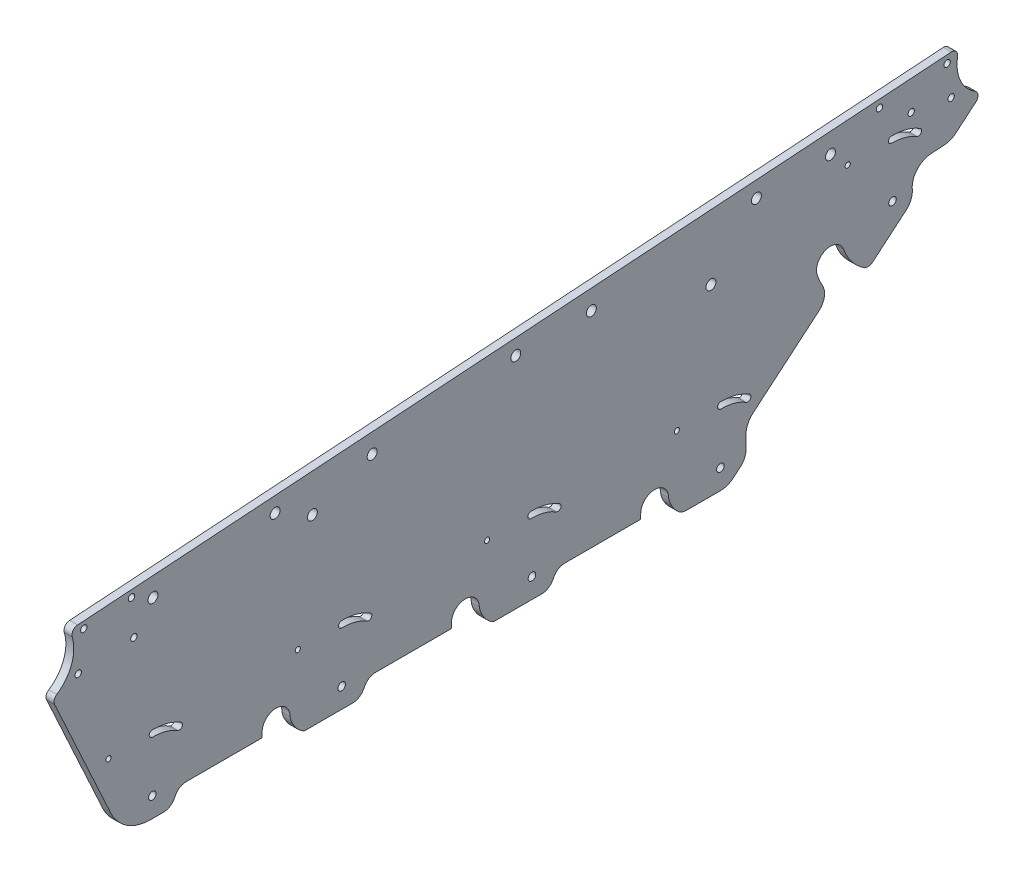
from build123d import *

# Parameters (mm, degrees)
SKETCH_1_R      = 2.5
SKETCH_1_R_2    = 1.6
SKETCH_1_R_3    = 1.3
SKETCH_1_R_4    = 1.9
EXTRUDE_1_DEPTH = 4


with BuildPart() as part:
    # 草图1 → 凸台-拉伸1 (new body)
    with BuildSketch(Plane.ZY):
        with BuildLine():
            Line((79.941847196, 312.779286974), (79.941847196, 310.37938842))
            Line((79.941847196, 310.37938842), (118.048778684, 310.37938842))
            ThreePointArc((118.048778684, 310.37938842), (121.212295154, 309.477639448), (123.424912382, 307.043442935))
            ThreePointArc((123.424912382, 307.043442935), (123.908451597, 306.156590075), (124.459804418, 305.310228312))
            ThreePointArc((124.459804418, 305.310228312), (126.599767036, 303.449448704), (129.355274977, 302.779286974))
            Line((129.355274977, 302.779286974), (135.846674735, 302.779286974))
            ThreePointArc((135.846674735, 302.779286974), (147.714917725, 306.255118752), (155.832977431, 315.5843044))
            Line((155.832977431, 315.5843044), (184.100349844, 377.02653737))
            ThreePointArc((184.100349844, 377.02653737), (184.25423495, 379.122829036), (182.994670387, 380.805569803))
            ThreePointArc((182.994670387, 380.805569803), (175.575423742, 390.035917566), (175.217785471, 401.873004854))
            ThreePointArc((175.217785471, 401.873004854), (174.813539386, 404.446095635), (172.549129806, 405.733208807))
            Line((172.549129806, 405.733208807), (-265.913463366, 435.515010668))
            ThreePointArc((-265.913463366, 435.515010668), (-268.349260645, 434.525893618), (-269.070634733, 431.997835004))
            ThreePointArc((-269.070634733, 431.997835004), (-270.458967767, 420.871071163), (-277.882819523, 412.467573839))
            ThreePointArc((-277.882819523, 412.467573839), (-279.312515533, 410.13392022), (-278.252765969, 407.610648385))
            Line((-278.252765969, 407.610648385), (-268.246230566, 399.190213281))
            ThreePointArc((-268.246230566, 399.190213281), (-265.544431584, 397.566061892), (-262.471282959, 396.863678095))
            Line((-262.471282959, 396.863678095), (-255.629318556, 396.408593428))
            ThreePointArc((-255.629318556, 396.408593428), (-248.6530075, 392.882824378), (-246.344722675, 385.41477346))
            ThreePointArc((-246.344722675, 385.41477346), (-245.547224173, 381.106497376), (-242.780709967, 377.708903254))
            Line((-242.780709967, 377.708903254), (-225.96618646, 363.559589999))
            ThreePointArc((-225.96618646, 363.559589999), (-224.259021966, 363.148943594), (-222.527086507, 363.437804541))
            ThreePointArc((-222.527086507, 363.437804541), (-216.093640019, 369.198004343), (-211.901591148, 376.74756471))
            ThreePointArc((-211.901591148, 376.74756471), (-202.96771311, 381.012048641), (-198.703229179, 372.078170603))
            ThreePointArc((-198.703229179, 372.078170603), (-199.907426668, 369.068297365), (-201.351406018, 366.165823913))
            ThreePointArc((-201.351406018, 366.165823913), (-202.203284687, 360.847165515), (-199.49001514, 356.193995329))
            Line((-199.49001514, 356.193995329), (-166.466058225, 328.404548243))
            ThreePointArc((-166.466058225, 328.404548243), (-163.838636178, 324.972953793), (-162.904676824, 320.753130691))
            Line((-162.904676824, 320.753130691), (-162.904676824, 314.217366152))
            ThreePointArc((-162.904676824, 314.217366152), (-162.15750934, 310.841507671), (-160.055571702, 308.096232111))
            Line((-160.055571702, 308.096232111), (-156.52807865, 305.127869423))
            ThreePointArc((-156.52807865, 305.127869423), (-153.516253341, 303.384762625), (-150.089460052, 302.779286974))
            Line((-150.089460052, 302.779286974), (-132.962822931, 302.779286974))
            ThreePointArc((-132.962822931, 302.779286974), (-131.057359543, 303.089892518), (-129.349178653, 303.989550548))
            ThreePointArc((-129.349178653, 303.989550548), (-127.378799895, 305.843763559), (-125.854682643, 308.079286974))
            ThreePointArc((-125.854682643, 308.079286974), (-124.70730834, 310.334067306), (-124.058152804, 312.779286974))
            ThreePointArc((-124.058152804, 312.779286974), (-117.058152804, 319.779286974), (-110.058152804, 312.779286974))
            Line((-110.058152804, 312.779286974), (-110.058152804, 310.375194841))
            Line((-110.058152804, 310.375194841), (-71.897768127, 310.375194841))
            ThreePointArc((-71.897768127, 310.375194841), (-68.768086545, 309.494285893), (-66.557393134, 307.110225907))
            ThreePointArc((-66.557393134, 307.110225907), (-65.945300527, 306.047683601), (-65.231544729, 305.050584724))
            ThreePointArc((-65.231544729, 305.050584724), (-63.141167069, 303.376870223), (-60.530823557, 302.779286974))
            Line((-60.530823557, 302.779286974), (-36.305637158, 302.779286974))
            ThreePointArc((-36.305637158, 302.779286974), (-33.16644373, 305.003787341), (-30.854682657, 308.079286974))
            ThreePointArc((-30.854682657, 308.079286974), (-29.707305648, 310.334074366), (-29.058150487, 312.779301913))
            ThreePointArc((-29.058150487, 312.779301913), (-22.058145334, 319.779284657), (-15.058155121, 312.779286974))
            Line((-15.058155121, 312.779286974), (-15.058155121, 310.354804619))
            Line((-15.058155121, 310.354804619), (23.075565874, 310.354804619))
            ThreePointArc((23.075565874, 310.354804619), (26.234507213, 309.455891721), (28.446910847, 307.028501158))
            ThreePointArc((28.446910847, 307.028501158), (28.930044794, 306.145924462), (29.48046838, 305.303669209))
            ThreePointArc((29.48046838, 305.303669209), (31.619349297, 303.447603066), (34.37128438, 302.779286974))
            Line((34.37128438, 302.779286974), (58.694362842, 302.779286974))
            ThreePointArc((58.694362842, 302.779286974), (61.833556273, 305.00378734), (64.14531735, 308.079286974))
            ThreePointArc((64.14531735, 308.079286974), (65.292691668, 310.334067319), (65.941847214, 312.779287004))
            ThreePointArc((65.941847214, 312.779287004), (72.94184722, 319.77928698), (79.941847196, 312.779286974))
        make_face()
        with Locations((134.697589837, 398.714435962)):
            Circle(SKETCH_1_R, mode=Mode.SUBTRACT)
        with Locations((-205.302410163, 421.329108832)):
            Circle(SKETCH_1_R, mode=Mode.SUBTRACT)
        with Locations((24.697589837, 406.030947773)):
            Circle(SKETCH_1_R, mode=Mode.SUBTRACT)
        with Locations((54.697589837, 394.714435962)):
            Circle(SKETCH_1_R, mode=Mode.SUBTRACT)
        with Locations((-145.302410163, 394.714435962)):
            Circle(SKETCH_1_R, mode=Mode.SUBTRACT)
        with Locations((-85.302410163, 413.347459584)):
            Circle(SKETCH_1_R, mode=Mode.SUBTRACT)
        with Locations((-229.912547558, 429.226877683)):
            Circle(SKETCH_1_R_2, mode=Mode.SUBTRACT)
        with Locations((-263.830685058, 431.584832)):
            Circle(SKETCH_1_R_2, mode=Mode.SUBTRACT)
        with Locations((-245.82758059, 419.331621378)):
            Circle(SKETCH_1_R_2, mode=Mode.SUBTRACT)
        with Locations((-213.924753581, 412.419296618)):
            Circle(SKETCH_1_R_3, mode=Mode.SUBTRACT)
        with Locations((-265.82758059, 415.709933316)):
            Circle(SKETCH_1_R_2, mode=Mode.SUBTRACT)
        with Locations((145.452321386, 404.165877908)):
            Circle(SKETCH_1_R_2, mode=Mode.SUBTRACT)
        with Locations((172.223627163, 384.384644706)):
            Circle(SKETCH_1_R_2, mode=Mode.SUBTRACT)
        with Locations((169.397149412, 402.539467503)):
            Circle(SKETCH_1_R_2, mode=Mode.SUBTRACT)
        with Locations((144.282792088, 386.203912503)):
            Circle(SKETCH_1_R_2, mode=Mode.SUBTRACT)
        with Locations((-236.412834805, 385.419296624)):
            Circle(SKETCH_1_R_4, mode=Mode.SUBTRACT)
        with Locations((-128.211318153, 339.779286974)):
            Circle(SKETCH_1_R_3, mode=Mode.SUBTRACT)
        with Locations((62, 339.779286968)):
            Circle(SKETCH_1_R_3, mode=Mode.SUBTRACT)
        with Locations((40, 312.779286974)):
            Circle(SKETCH_1_R_4, mode=Mode.SUBTRACT)
        with Locations((-47.3651173, 412.828527404)):
            Circle(SKETCH_1_R, mode=Mode.SUBTRACT)
        with Locations((-55.488081224, 312.779286974)):
            Circle(SKETCH_1_R_4, mode=Mode.SUBTRACT)
        with Locations((-33, 339.779286968)):
            Circle(SKETCH_1_R_3, mode=Mode.SUBTRACT)
        with Locations((-168.130178692, 420.86106375)):
            Circle(SKETCH_1_R, mode=Mode.SUBTRACT)
        with Locations((73.399944092, 404.795991058)):
            Circle(SKETCH_1_R, mode=Mode.SUBTRACT)
        with Locations((157, 339.779286968)):
            Circle(SKETCH_1_R_3, mode=Mode.SUBTRACT)
        with Locations((-150.058152804, 312.779286974)):
            Circle(SKETCH_1_R_4, mode=Mode.SUBTRACT)
        with Locations((135, 312.779286974)):
            Circle(SKETCH_1_R_4, mode=Mode.SUBTRACT)
        with BuildLine():
            ThreePointArc((-235.893747688, 414.018996163), (-243.357483185, 413.10813588), (-250.274012295, 410.158790343))
            ThreePointArc((-250.274012295, 410.158790343), (-250.815185629, 407.961716967), (-248.618112252, 407.420543633))
            ThreePointArc((-248.618112252, 407.420543633), (-242.527853555, 410.017551036), (-235.955759474, 410.819597073))
            ThreePointArc((-235.955759474, 410.819597073), (-234.325054036, 412.388290724), (-235.893747688, 414.018996163))
        make_face(mode=Mode.SUBTRACT)
        with BuildLine():
            ThreePointArc((-54.968994107, 341.378986513), (-62.432729604, 340.468126231), (-69.349258714, 337.518780694))
            ThreePointArc((-69.349258714, 337.518780694), (-69.890432048, 335.321707317), (-67.693358671, 334.780533983))
            ThreePointArc((-67.693358671, 334.780533983), (-61.603099974, 337.377541387), (-55.031005893, 338.179587423))
            ThreePointArc((-55.031005893, 338.179587423), (-53.400300455, 339.748281075), (-54.968994107, 341.378986513))
        make_face(mode=Mode.SUBTRACT)
        with BuildLine():
            ThreePointArc((-150.180312259, 341.378986519), (-157.644047756, 340.468126237), (-164.560576866, 337.5187807))
            ThreePointArc((-164.560576866, 337.5187807), (-165.1017502, 335.321707323), (-162.904676824, 334.780533989))
            ThreePointArc((-162.904676824, 334.780533989), (-156.814418127, 337.377541393), (-150.242324046, 338.179587429))
            ThreePointArc((-150.242324046, 338.179587429), (-148.611618608, 339.748281081), (-150.180312259, 341.378986519))
        make_face(mode=Mode.SUBTRACT)
        with BuildLine():
            ThreePointArc((40.031005893, 341.378986519), (32.567270396, 340.468126237), (25.650741286, 337.5187807))
            ThreePointArc((25.650741286, 337.5187807), (25.109567952, 335.321707323), (27.306641329, 334.780533989))
            ThreePointArc((27.306641329, 334.780533989), (33.396900026, 337.377541393), (39.968994107, 338.179587429))
            ThreePointArc((39.968994107, 338.179587429), (41.599699545, 339.748281081), (40.031005893, 341.378986519))
        make_face(mode=Mode.SUBTRACT)
        with BuildLine():
            ThreePointArc((135.031005893, 341.378986513), (127.567270396, 340.468126231), (120.650741287, 337.518780694))
            ThreePointArc((120.650741287, 337.518780694), (120.109567952, 335.321707317), (122.306641329, 334.780533983))
            ThreePointArc((122.306641329, 334.780533983), (128.396900026, 337.377541387), (134.968994107, 338.179587423))
            ThreePointArc((134.968994107, 338.179587423), (136.599699545, 339.748281075), (135.031005893, 341.378986513))
        make_face(mode=Mode.SUBTRACT)
    extrude(amount=EXTRUDE_1_DEPTH)


solid = part.part
